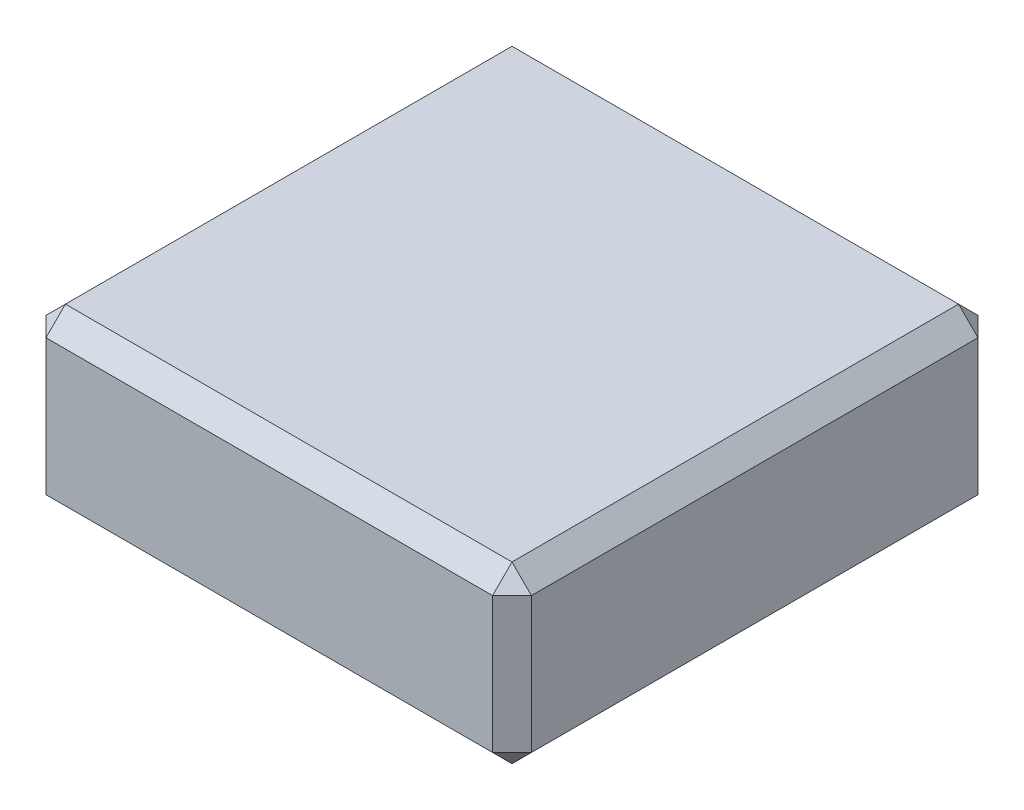
from build123d import *

# Parameters (mm, degrees)
SKETCH1_W           = 50
SKETCH1_H           = 50
BOSS_EXTRUDE1_DEPTH = 18
CHAMFER1_SIZE       = 2


with BuildPart() as part:
    # Sketch1 → Boss-Extrude1 (new body)
    with BuildSketch(Plane(origin=(0, 0, 0), x_dir=(1, 0, 0), z_dir=(0, 1, 0))):
        with Locations((25, -25)):
            Rectangle(SKETCH1_W, SKETCH1_H)
    extrude(amount=BOSS_EXTRUDE1_DEPTH)

    # Chamfer1
    chamfer1_edges = [part.edges().sort_by_distance(p)[0] for p in [
        (50, 18, 25),
        (25, 18, 0),
        (0, 18, 25),
        (25, 0, 0),
        (50, 0, 25),
        (25, 0, 50),
        (0, 0, 25),
        (25, 18, 50),
        (0, 9, 0),
        (50, 9, 0),
        (50, 9, 50),
        (0, 9, 50),
    ]]
    chamfer(chamfer1_edges, length=CHAMFER1_SIZE)


solid = part.part
